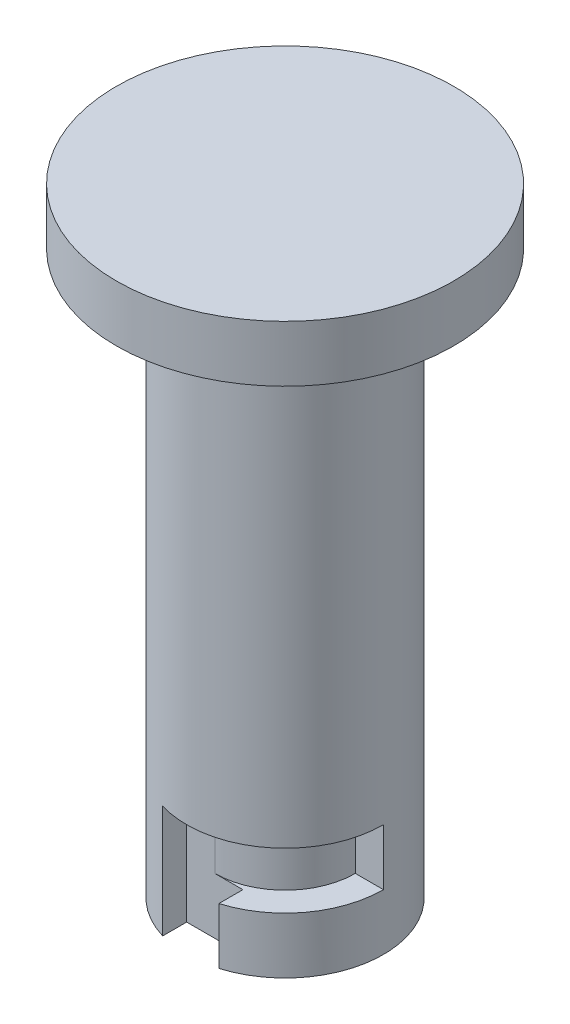
from build123d import *

# Parameters (mm, degrees)
SKETCH1_R           = 3.5
BOSS_EXTRUDE1_DEPTH = 20
SKETCH2_R           = 6
BOSS_EXTRUDE2_DEPTH = 2
CUT_EXTRUDE1_DEPTH  = 4
SKETCH6_W           = 1
SKETCH6_H           = 2
CUT_REVOLVE1_ANGLE  = 90


with BuildPart() as part:
    # Sketch1 → Boss-Extrude1 (new body)
    with BuildSketch(Plane(origin=(0, 0, 0), x_dir=(1, 0, 0), z_dir=(0, 1, 0))):
        Circle(SKETCH1_R)
    extrude(amount=BOSS_EXTRUDE1_DEPTH)

    # Sketch2 → Boss-Extrude2 (add)
    with BuildSketch(Plane(origin=(0, 20, 0), x_dir=(1, 0, 0), z_dir=(0, 1, 0))):
        Circle(SKETCH2_R)
    extrude(amount=BOSS_EXTRUDE2_DEPTH)

    # Sketch3 → Cut-Extrude1 (cut)
    with BuildSketch(Plane.XZ):
        Polygon((0, 3.5), (-1, 3.5), (-1, 2.5), (1, 2.5), (1, 3.5), align=None)
        Polygon((-1, -3.5), (-1, -2.5), (1, -2.5), (1, -3.5), (0, -3.5), align=None)
    extrude(amount=-CUT_EXTRUDE1_DEPTH, mode=Mode.SUBTRACT)

    # Sketch6 → Cut-Revolve1 (revolve, cut)
    with BuildSketch(Plane(origin=(0, 0, 0), x_dir=(0, 0, -1), z_dir=(1, 0, 0))):
        with Locations((3, 3)):
            Rectangle(SKETCH6_W, SKETCH6_H)
        with Locations((-3, 3)):
            Rectangle(SKETCH6_W, SKETCH6_H)
    revolve(axis=Axis((0, 0, 0), (0, 1, 0)), revolution_arc=CUT_REVOLVE1_ANGLE, mode=Mode.SUBTRACT)


solid = part.part
